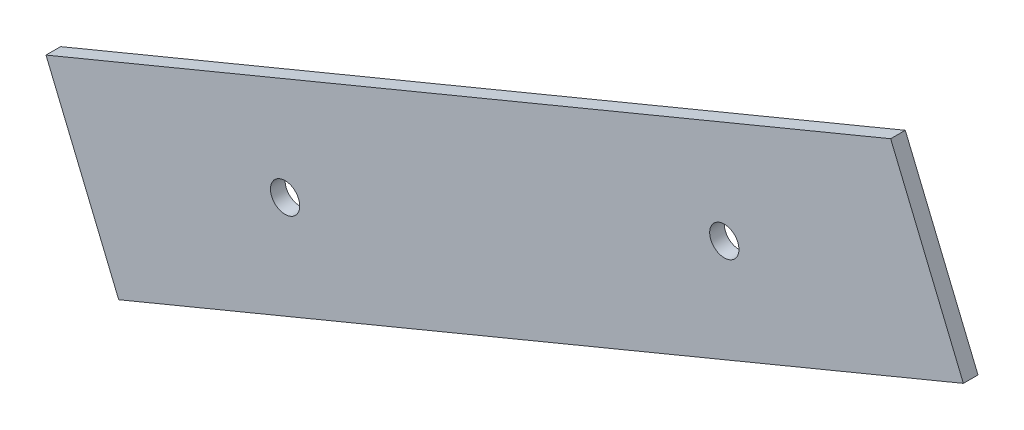
from build123d import *

# Parameters (mm, degrees)
SKETCH1_R           = 2
BOSS_EXTRUDE1_DEPTH = 2


with BuildPart() as part:
    # Sketch1 → Boss-Extrude1 (new body)
    with BuildSketch(Plane.XY):
        Polygon((-56.791123045, -16.390968889), (-46.849643213, -40.39182433), (68.635298351, 7.443604716), (58.693818519, 31.444460156), align=None)
        with Locations((-24.103997154, -16.910893639)):
            Circle(SKETCH1_R, mode=Mode.SUBTRACT)
        with Locations((35.94817246, 7.963529465)):
            Circle(SKETCH1_R, mode=Mode.SUBTRACT)
    extrude(amount=BOSS_EXTRUDE1_DEPTH)


solid = part.part
